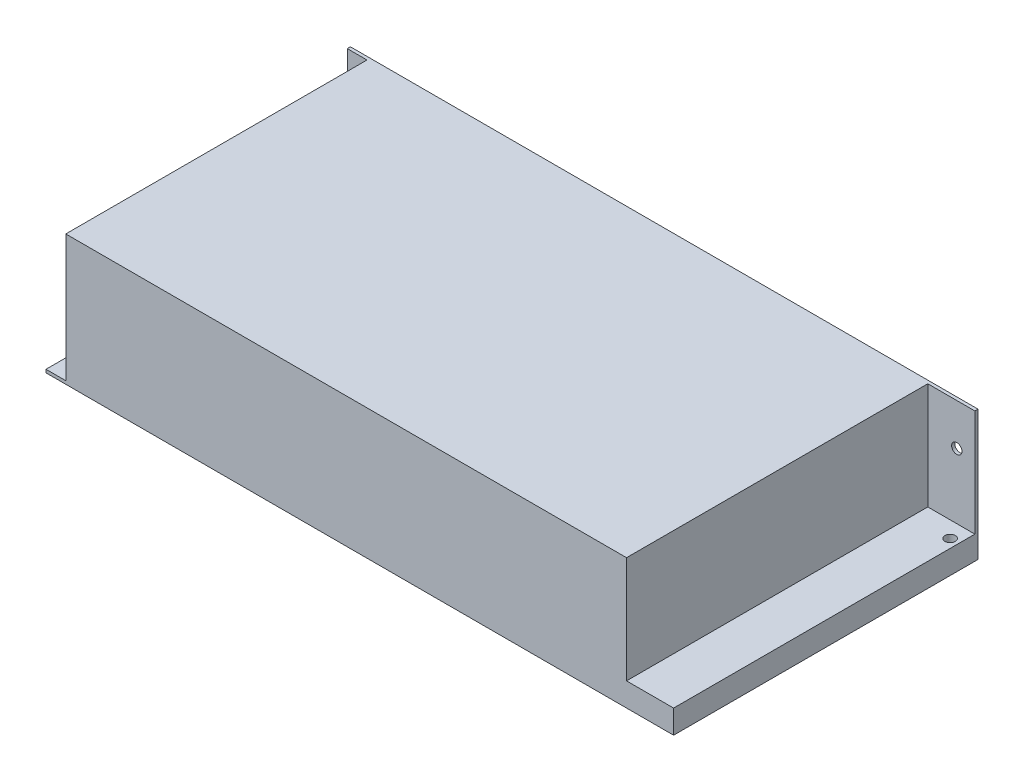
from build123d import *

# Parameters (mm, degrees)
SKETCH1_W           = 200
SKETCH1_H           = 97
BOSS_EXTRUDE1_DEPTH = 20.75
SKETCH2_W           = 15
SKETCH2_H           = 96
CUT_EXTRUDE1_DEPTH  = 34
SKETCH3_W           = 6.3
SKETCH3_H           = 96
CUT_EXTRUDE2_DEPTH  = 40.5
SKETCH4_R           = 1.65
CUT_EXTRUDE3_DEPTH  = 2
SKETCH5_R           = 1.65
CUT_EXTRUDE4_DEPTH  = 42.5


with BuildPart() as part:
    # Sketch1 → Boss-Extrude1 (new body, symmetric)
    with BuildSketch(Plane(origin=(0, 0, 0), x_dir=(1, 0, 0), z_dir=(0, 1, 0))):
        Rectangle(SKETCH1_W, SKETCH1_H)
    extrude(amount=BOSS_EXTRUDE1_DEPTH, both=True)

    # Sketch2 → Cut-Extrude1 (cut)
    with BuildSketch(Plane(origin=(0, 20.75, 0), x_dir=(1, 0, 0), z_dir=(0, 1, 0))):
        with Locations((92.5, -0.5)):
            Rectangle(SKETCH2_W, SKETCH2_H)
    extrude(amount=-CUT_EXTRUDE1_DEPTH, mode=Mode.SUBTRACT)

    # Sketch3 → Cut-Extrude2 (cut)
    with BuildSketch(Plane(origin=(0, 20.75, 0), x_dir=(1, 0, 0), z_dir=(0, 1, 0))):
        with Locations((-96.85, -0.5)):
            Rectangle(SKETCH3_W, SKETCH3_H)
    extrude(amount=-CUT_EXTRUDE2_DEPTH, mode=Mode.SUBTRACT)

    # Sketch4 → Cut-Extrude3 (cut, through all)
    with BuildSketch(Plane.XY.offset(-47.5)):
        with Locations((94.25, 7.5)):
            Circle(SKETCH4_R)
        with BuildLine():
            Line((-96.35, 9.25), (-100, 9.25))
            Line((-100, 9.25), (-100, 5.95))
            Line((-100, 5.95), (-96.35, 5.95))
            ThreePointArc((-96.35, 5.95), (-94.7, 7.6), (-96.35, 9.25))
        make_face()
    extrude(amount=-CUT_EXTRUDE3_DEPTH, mode=Mode.SUBTRACT)

    # Sketch5 → Cut-Extrude4 (cut, through all)
    with BuildSketch(Plane.XZ.offset(20.75)):
        with Locations((97.25, -42.35)):
            Circle(SKETCH5_R)
    extrude(amount=-CUT_EXTRUDE4_DEPTH, mode=Mode.SUBTRACT)


solid = part.part
